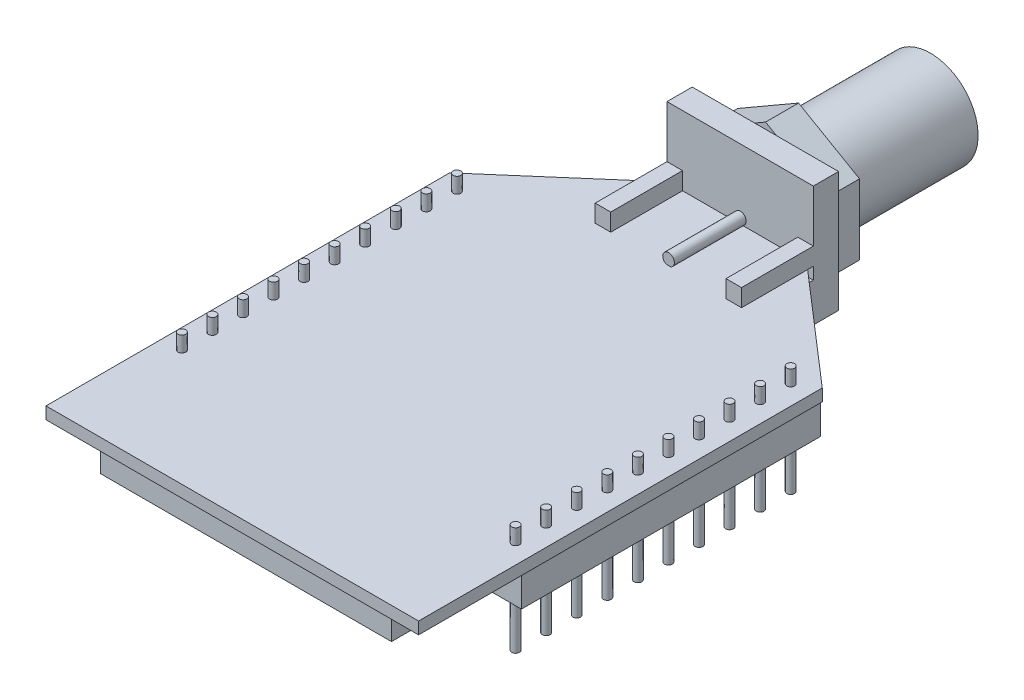
from build123d import *

# Parameters (mm, degrees)
BASE_PCB_DEPTH                      = 0.7874
SKETCH2_R                           = 0.254
HEADER_HOLE_DEPTH                   = 1.7874
F_2MM_HEADER_PATTERN_COUNT          = 10
F_2MM_HEADER_PATTERN_PITCH          = 2
F_2MM_HEADER_PATTERN_COUNT_DIR2     = 2
F_2MM_HEADER_PATTERN_PITCH_DIR2     = 21.844
SKETCH3_W                           = 19.05
SKETCH3_H                           = 24.13
WIRELESS_MODULE_DEPTH               = 2.032
HEADER_START                        = -6.096
SKETCH12_R                          = 0.254
HEADER_PIN_DEPTH                    = 7.112
F_2MM_HEADER_PIN_PATTERN_COUNT      = 10
F_2MM_HEADER_PIN_PATTERN_PITCH      = 2
F_2MM_HEADER_PIN_PATTERN_COUNT_DIR2 = 2
F_2MM_HEADER_PIN_PATTERN_PITCH_DIR2 = 21.844
SKETCH13_W                          = 2.159
SKETCH13_H                          = 19.558
HEADER_BOSS_DEPTH                   = 2.032
HEADER_BOSS_PATTERN_COUNT           = 2
HEADER_BOSS_PATTERN_PITCH           = 21.844
SKETCH4_W                           = 9.5758
SKETCH4_H                           = 7.874
SMA_BASE_DEPTH                      = 1.651
SKETCH5_W                           = 1.016
SKETCH5_H                           = 2.54
SMA_PRONGS_BOTTOM_DEPTH             = 4.699
SKETCH6_W                           = 1.016
SKETCH6_H                           = 1.143
SMA_PRONGS_TOP_DEPTH                = 4.699
SKETCH7_R                           = 0.381
SMA_CENTER_PIN_DEPTH                = 4.699
SMA_CENTER_PIN_DEPTH_BACK           = 13.208
SMA_NUT_DEPTH                       = 2.159
SKETCH10_R                          = 3.1115
RPSMA_BARREL_DEPTH                  = 8.636
SKETCH11_R                          = 2.286
SKETCH11_R_2                        = 0.381
CUT_EXTRUDE4_DEPTH                  = 2.032


with BuildPart() as part:
    # Sketch1 → Base PCB (new body)
    with BuildSketch(Plane(origin=(0, 0, 0), x_dir=(1, 0, 0), z_dir=(0, 1, 0))):
        Polygon((0, 26.416), (7.62, 33.02), (16.764, 33.02), (24.384, 26.416), (24.384, 0), (0, 0), align=None)
    extrude(amount=BASE_PCB_DEPTH)

    # Sketch2 → Header Hole (cut, through all)
    with BuildSketch(Plane(origin=(0, 0.7874, 0), x_dir=(1, 0, 0), z_dir=(0, 1, 0))):
        with Locations((1.27, 7.62)):
            Circle(SKETCH2_R)
    header_hole = extrude(amount=-HEADER_HOLE_DEPTH, mode=Mode.SUBTRACT)

    # 2mm Header pattern: Header Hole 10 × 2
    with Locations(*[(j * F_2MM_HEADER_PATTERN_PITCH_DIR2, 0, -i * F_2MM_HEADER_PATTERN_PITCH) for i in range(F_2MM_HEADER_PATTERN_COUNT) for j in range(F_2MM_HEADER_PATTERN_COUNT_DIR2) if (i, j) != (0, 0)]):
        add(header_hole, mode=Mode.SUBTRACT)

    # Sketch3 → Wireless Module (add)
    with BuildSketch(Plane.XZ):
        with Locations((12.319, -12.827)):
            Rectangle(SKETCH3_W, SKETCH3_H)
    extrude(amount=WIRELESS_MODULE_DEPTH)

    # Sketch12 → Header Pin (add)
    with BuildSketch(Plane(origin=(0, 0.7874, 0), x_dir=(1, 0, 0), z_dir=(0, 1, 0)).offset(HEADER_START)):
        with Locations((1.27, 7.62)):
            Circle(SKETCH12_R)
    header_pin = extrude(amount=HEADER_PIN_DEPTH)

    # 2mm Header Pin pattern: Header Pin 10 × 2
    with Locations(*[(j * F_2MM_HEADER_PIN_PATTERN_PITCH_DIR2, 0, -i * F_2MM_HEADER_PIN_PATTERN_PITCH) for i in range(F_2MM_HEADER_PIN_PATTERN_COUNT) for j in range(F_2MM_HEADER_PIN_PATTERN_COUNT_DIR2) if (i, j) != (0, 0)]):
        add(header_pin)

    # Sketch13 → Header Boss (add)
    with BuildSketch(Plane.XZ):
        with Locations((23.1775, -16.637)):
            Rectangle(SKETCH13_W, SKETCH13_H)
    header_boss = extrude(amount=HEADER_BOSS_DEPTH)

    # Header Boss pattern: Header Boss ×2
    with Locations(*[(-i * HEADER_BOSS_PATTERN_PITCH, 0, 0) for i in range(1, HEADER_BOSS_PATTERN_COUNT)]):
        add(header_boss)

    # Sketch4 → SMA Base (add)
    with BuildSketch(Plane(origin=(0, 0, -33.02), x_dir=(-1, 0, 0), z_dir=(0, 0, -1))):
        with Locations((-12.4079, 1.397)):
            Rectangle(SKETCH4_W, SKETCH4_H)
    extrude(amount=SMA_BASE_DEPTH)

    # Sketch5 → SMA Prongs-bottom (add)
    with BuildSketch(Plane.XY.offset(-33.02)):
        with Locations((8.128, -1.27)):
            Rectangle(SKETCH5_W, SKETCH5_H)
        with Locations((16.6878, -1.27)):
            Rectangle(SKETCH5_W, SKETCH5_H)
    extrude(amount=SMA_PRONGS_BOTTOM_DEPTH)

    # Sketch6 → SMA Prongs-top (add)
    with BuildSketch(Plane.XY.offset(-33.02)):
        with Locations((8.128, 1.3589)):
            Rectangle(SKETCH6_W, SKETCH6_H)
        with Locations((16.6878, 1.3589)):
            Rectangle(SKETCH6_W, SKETCH6_H)
    extrude(amount=SMA_PRONGS_TOP_DEPTH)

    # Sketch7 → SMA Center Pin (add, two sides)
    with BuildSketch(Plane.XY.offset(-33.02)) as sma_center_pin_sk:
        with Locations((12.4206, 1.143)):
            Circle(SKETCH7_R)
    extrude(amount=SMA_CENTER_PIN_DEPTH)
    extrude(sma_center_pin_sk.sketch, amount=-SMA_CENTER_PIN_DEPTH_BACK)

    # Sketch9 → SMA Nut (add)
    with BuildSketch(Plane(origin=(0, 0, -34.671), x_dir=(-1, 0, 0), z_dir=(0, 0, -1))):
        Polygon((-12.4206, 5.747714807), (-16.4084, 3.445357403), (-16.4084, -1.159357403), (-12.4206, -3.461714807), (-8.4328, -1.159357403), (-8.4328, 3.445357403), align=None)
    extrude(amount=SMA_NUT_DEPTH)

    # Sketch10 → RPSMA Barrel (add)
    with BuildSketch(Plane(origin=(0, 0, -36.83), x_dir=(-1, 0, 0), z_dir=(0, 0, -1))):
        with Locations((-12.4206, 1.143)):
            Circle(SKETCH10_R)
    extrude(amount=RPSMA_BARREL_DEPTH)

    # Sketch11 → Cut-Extrude4 (cut)
    with BuildSketch(Plane(origin=(0, 0, -45.466), x_dir=(-1, 0, 0), z_dir=(0, 0, -1))):
        with Locations((-12.4206, 1.143)):
            Circle(SKETCH11_R)
        with Locations((-12.4206, 1.143)):
            Circle(SKETCH11_R_2, mode=Mode.SUBTRACT)
    extrude(amount=-CUT_EXTRUDE4_DEPTH, mode=Mode.SUBTRACT)


solid = part.part
